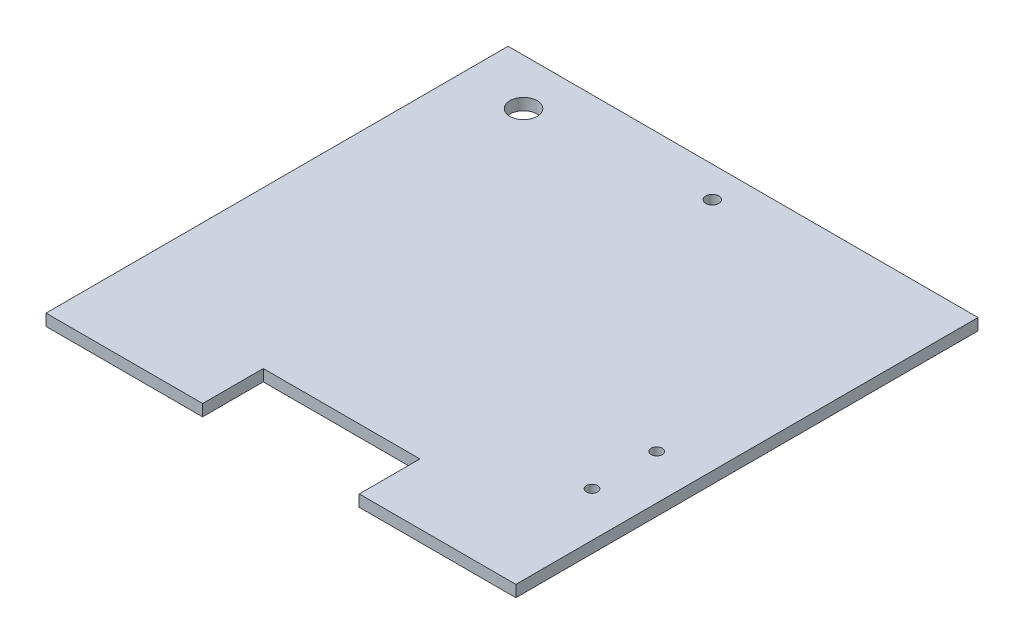
from build123d import *

# Parameters (mm, degrees)
SKETCH1_W           = 193.68
SKETCH1_H           = 190.5
BOSS_EXTRUDE1_DEPTH = 4.78
SKETCH2_R           = 2.6797
CUT_EXTRUDE1_DEPTH  = 5.78
CUT_EXTRUDE2_DEPTH  = 5.78
SKETCH5_R           = 2.286
SKETCH5_R_2         = 5.6134
CUT_EXTRUDE3_DEPTH  = 5.78


with BuildPart() as part:
    # Sketch1 → Boss-Extrude1 (new body)
    with BuildSketch(Plane(origin=(0, 0, 0), x_dir=(1, 0, 0), z_dir=(0, 1, 0))):
        Rectangle(SKETCH1_W, SKETCH1_H)
    extrude(amount=BOSS_EXTRUDE1_DEPTH)

    # Sketch2 → Cut-Extrude1 (cut, through all)
    with BuildSketch(Plane(origin=(0, 4.78, 0), x_dir=(1, 0, 0), z_dir=(0, 1, 0))):
        with Locations((0, 82.55)):
            Circle(SKETCH2_R)
    extrude(amount=-CUT_EXTRUDE1_DEPTH, mode=Mode.SUBTRACT)

    # Sketch3 → Cut-Extrude2 (cut, through all)
    with BuildSketch(Plane(origin=(0, 4.78, 0), x_dir=(1, 0, 0), z_dir=(0, 1, 0))):
        Polygon((0, -95.25), (-32.28, -95.25), (-32.28, -70.249999962), (32.28, -70.249999962), (32.28, -95.25), align=None)
    extrude(amount=-CUT_EXTRUDE2_DEPTH, mode=Mode.SUBTRACT)

    # Sketch5 → Cut-Extrude3 (cut, through all)
    with BuildSketch(Plane(origin=(0, 4.78, 0), x_dir=(1, 0, 0), z_dir=(0, 1, 0))):
        with Locations((78.425, -18.77099)):
            Circle(SKETCH5_R)
        with Locations((78.425, -45.44099)):
            Circle(SKETCH5_R)
        with Locations((-71.44, 76.2)):
            Circle(SKETCH5_R_2)
    extrude(amount=-CUT_EXTRUDE3_DEPTH, mode=Mode.SUBTRACT)


solid = part.part
